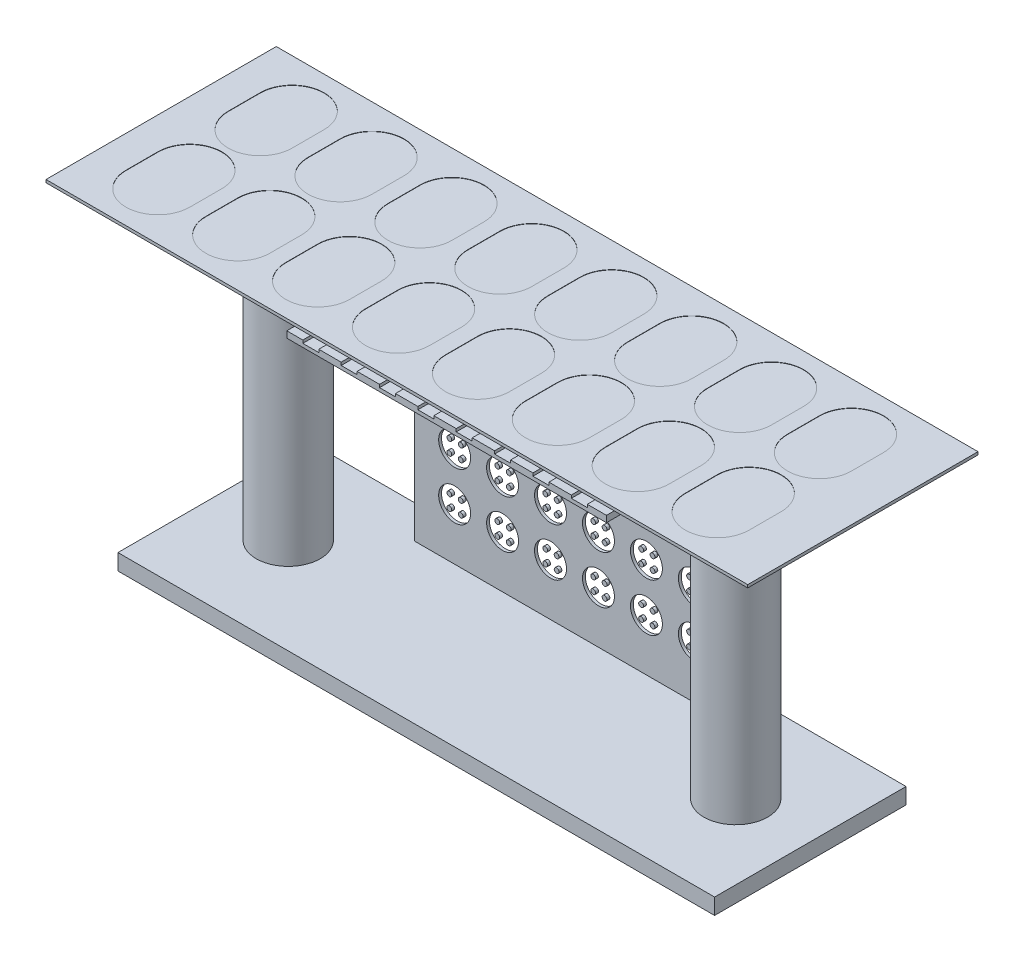
from build123d import *

# Parameters (mm, degrees)
SKETCH3_W             = 10000
SKETCH3_H             = 8000
BOSS_EXTRUDE1_DEPTH   = 90
SKETCH6_W             = 10000
SKETCH6_H             = 4000
BOSS_EXTRUDE2_DEPTH   = 200
SKETCH7_R             = 500
SKETCH7_R_2           = 75
CUT_EXTRUDE4_DEPTH    = 91
LPATTERN1_COUNT       = 6
LPATTERN1_PITCH       = 1500
LPATTERN1_COUNT_DIR2  = 4
LPATTERN1_PITCH_DIR2  = 1500
SKETCH11_R            = 1000
BOSS_EXTRUDE3_DEPTH   = 10000
BOSS_EXTRUDE3_2_DEPTH = 10000
SKETCH13_W            = 18666.837108976
SKETCH13_H            = 5990.503599442
BOSS_EXTRUDE4_DEPTH   = 500
SKETCH14_W            = 500
SKETCH14_H            = 4000
CUT_EXTRUDE5_DEPTH    = 90
LPATTERN2_COUNT       = 8
LPATTERN2_PITCH       = 1200
SKETCH17_W            = 21954.034670768
SKETCH17_H            = 7204.554013404
BOSS_EXTRUDE5_DEPTH   = 90
CUT_EXTRUDE6_DEPTH    = 10
LPATTERN3_COUNT       = 8
LPATTERN3_PITCH       = 2500
LPATTERN3_COUNT_DIR2  = 2
LPATTERN3_PITCH_DIR2  = 3200


with BuildPart() as part:
    # Sketch3 → Boss-Extrude1 (new body)
    with BuildSketch(Plane.XY):
        Rectangle(SKETCH3_W, SKETCH3_H)
    extrude(amount=BOSS_EXTRUDE1_DEPTH)

    # Sketch7 → Cut-Extrude4 (cut, through all)
    with BuildSketch(Plane.XY.offset(90)):
        with Locations((-3750, 2623.598588471)):
            Circle(SKETCH7_R)
        with Locations((-3915.851686394, 2823.598588471)):
            Circle(SKETCH7_R_2, mode=Mode.SUBTRACT)
        with Locations((-3559.179807494, 2823.598588471)):
            Circle(SKETCH7_R_2, mode=Mode.SUBTRACT)
        with Locations((-3559.179807494, 2423.598588471)):
            Circle(SKETCH7_R_2, mode=Mode.SUBTRACT)
        with Locations((-3915.851686394, 2423.598588471)):
            Circle(SKETCH7_R_2, mode=Mode.SUBTRACT)
    cut_extrude4 = extrude(amount=-CUT_EXTRUDE4_DEPTH, mode=Mode.SUBTRACT)

    # LPattern1: Cut-Extrude4 6 × 4
    with Locations(*[(i * LPATTERN1_PITCH, -j * LPATTERN1_PITCH_DIR2, 0) for i in range(LPATTERN1_COUNT) for j in range(LPATTERN1_COUNT_DIR2) if (i, j) != (0, 0)]):
        add(cut_extrude4, mode=Mode.SUBTRACT)



with BuildPart() as body_2:
    # Sketch6 → Boss-Extrude2 (new body)
    with BuildSketch(Plane(origin=(0, 4000, 0), x_dir=(1, 0, 0), z_dir=(0, 1, 0))):
        with Locations((0, -2090)):
            Rectangle(SKETCH6_W, SKETCH6_H)
    extrude(amount=BOSS_EXTRUDE2_DEPTH)

    # Sketch14 → Cut-Extrude5 (cut)
    with BuildSketch(Plane(origin=(0, 4200, 0), x_dir=(1, 0, 0), z_dir=(0, 1, 0))):
        with Locations((-4250, -2090)):
            Rectangle(SKETCH14_W, SKETCH14_H)
    cut_extrude5 = extrude(amount=-CUT_EXTRUDE5_DEPTH, mode=Mode.SUBTRACT)

    # LPattern2: Cut-Extrude5 ×8
    with Locations(*[(i * LPATTERN2_PITCH, 0, 0) for i in range(1, LPATTERN2_COUNT)]):
        add(cut_extrude5, mode=Mode.SUBTRACT)


with BuildPart() as body_3:
    # Sketch11 → Boss-Extrude3 (new body)
    with BuildSketch(Plane(origin=(0, -4000, 0), x_dir=(1, 0, 0), z_dir=(0, 1, 0))):
        with Locations((7000, -2045)):
            Circle(SKETCH11_R)
    extrude(amount=BOSS_EXTRUDE3_DEPTH)


with BuildPart() as body_4:
    # Sketch11 → Boss-Extrude3 2 (new body)
    with BuildSketch(Plane(origin=(0, -4000, 0), x_dir=(1, 0, 0), z_dir=(0, 1, 0))):
        with Locations((-7000, -2045)):
            Circle(SKETCH11_R)
    extrude(amount=BOSS_EXTRUDE3_2_DEPTH)


with BuildPart() as part_1:
    add(part.part)

    add(body_3.part)  # Boss-Extrude4 merges body 3

    add(body_4.part)  # Boss-Extrude4 merges body 4
    # Sketch13 → Boss-Extrude4 (add)
    with BuildSketch(Plane(origin=(0, -4000, 0), x_dir=(1, 0, 0), z_dir=(0, 1, 0))):
        with Locations((0, -2045)):
            Rectangle(SKETCH13_W, SKETCH13_H)
    extrude(amount=BOSS_EXTRUDE4_DEPTH)

    # Sketch17 → Boss-Extrude5 (add)
    with BuildSketch(Plane(origin=(0, 6000, 0), x_dir=(1, 0, 0), z_dir=(0, 1, 0))):
        with Locations((0, -2045)):
            Rectangle(SKETCH17_W, SKETCH17_H)
    extrude(amount=BOSS_EXTRUDE5_DEPTH)

    # Sketch19 → Cut-Extrude6 (cut)
    with BuildSketch(Plane(origin=(0, 6090, 0), x_dir=(1, 0, 0), z_dir=(0, 1, 0))):
        with BuildLine():
            Line((-9977.017335384, -4146.636209974), (-9977.017335384, -3146.636209974))
            ThreePointArc((-9977.017335384, -3146.636209974), (-8977.017335384, -2146.636209974), (-7977.017335384, -3146.636209974))
            Line((-7977.017335384, -3146.636209974), (-7977.017335384, -4146.636209974))
            ThreePointArc((-7977.017335384, -4146.636209974), (-8977.017335384, -5146.636209974), (-9977.017335384, -4146.636209974))
        make_face()
    cut_extrude6 = extrude(amount=-CUT_EXTRUDE6_DEPTH, mode=Mode.SUBTRACT)

    # LPattern3: Cut-Extrude6 8 × 2
    with Locations(*[(i * LPATTERN3_PITCH, 0, -j * LPATTERN3_PITCH_DIR2) for i in range(LPATTERN3_COUNT) for j in range(LPATTERN3_COUNT_DIR2) if (i, j) != (0, 0)]):
        add(cut_extrude6, mode=Mode.SUBTRACT)


solid = Compound([body_2.part, part_1.part])
